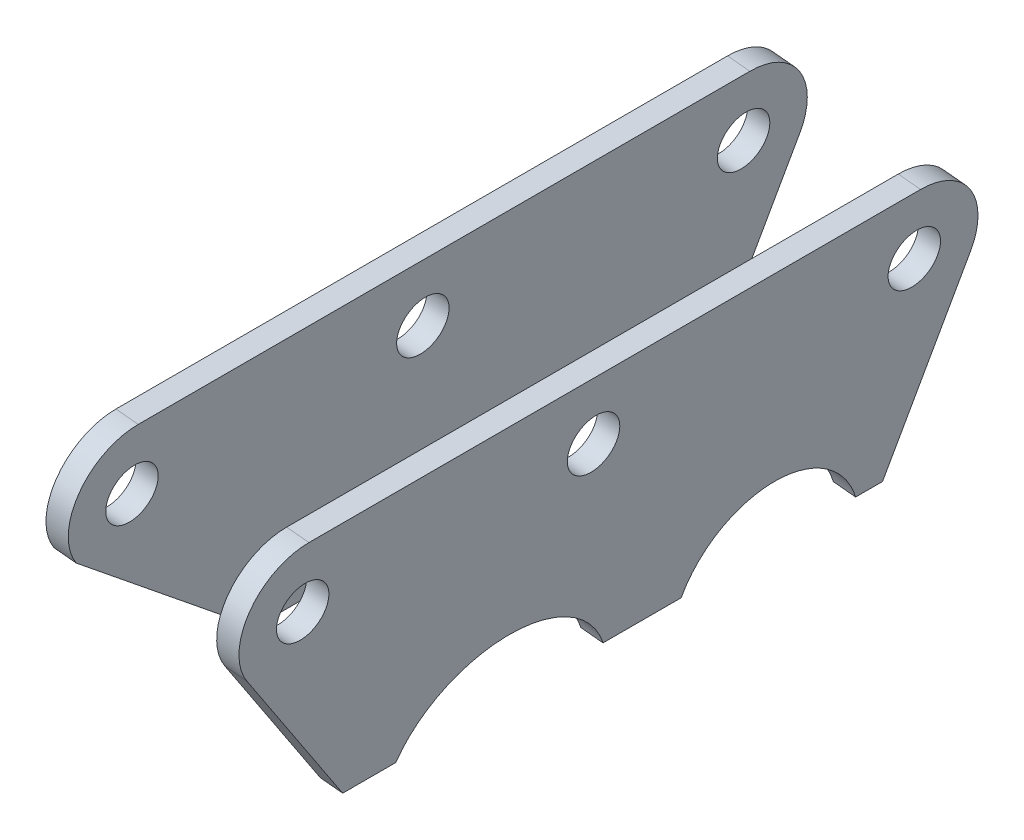
from build123d import *

# Parameters (mm, degrees)
SZKIC1_R                    = 3.5
DODANIE_WYCI_GNI_CIE1_DEPTH = 3
SZKIC2_R                    = 3.5
DODANIE_WYCI_GNI_CIE2_DEPTH = 3


with BuildPart() as part:
    # Szkic1 → Dodanie-wyciągnięcie1 (new body)
    with BuildSketch(Plane(origin=(1510.26539917, -150.162347119, 0), x_dir=(0, 0, -1), z_dir=(0.995093407, -0.098939936, 0))):
        with BuildLine():
            Line((-94, 389.244285112), (-176, 389.244285112))
            ThreePointArc((-176, 389.244285112), (-183.527682005, 384.691943106), (-182.99216801, 375.911109497))
            Line((-182.99216801, 375.911109497), (-168.015473067, 354.244285112))
            Line((-168.015473067, 354.244285112), (-160.885440505, 354.244285112))
            add(Edge.make_bspline(
                [(-160.885440505, 354.244285112), (-153.785636141, 368.019539208), (-137.697083979, 366.114436311), (-133.110394172, 354.244285112)],
                knots=[0.109763154, 0.109763154, 0.109763154, 0.109763154, 0.458625023, 0.458625023, 0.458625023, 0.458625023], degree=3, weights=[0.657330984, 0.39640678, 0.460028186, 0.848195201]))
            Line((-133.110394172, 354.244285112), (-122.632192473, 354.244285112))
            add(Edge.make_bspline(
                [(-122.632192473, 354.244285112), (-119.408973744, 362.626222554), (-111.475333465, 363.988172278), (-105.487616035, 361.094928434)],
                knots=[0.739553983, 0.739553983, 0.739553983, 0.739553983, 1, 1, 1, 1], degree=3, weights=[0.500872954, 0.486362962, 0.652738644, 1]))
            add(Edge.make_bspline(
                [(-105.487616035, 361.094928434), (-102.846358705, 359.818682251), (-100.484996274, 357.554609079), (-99.24420603, 354.244285112)],
                knots=[0, 0, 0, 0, 0.142552622, 0.142552622, 0.142552622, 0.142552622], degree=3, weights=[1, 0.809929837, 0.674049674, 0.592359511]))
            Line((-99.24420603, 354.244285112), (-95.633072844, 354.244285112))
            Line((-95.633072844, 354.244285112), (-86.130002131, 377.532878327))
            ThreePointArc((-86.130002131, 377.532878327), (-86.944967836, 385.485226069), (-94, 389.244285112))
        make_face()
        with Locations((-176, 380.744285112)):
            Circle(SZKIC1_R, mode=Mode.SUBTRACT)
        with Locations((-137, 380.744285112)):
            Circle(SZKIC1_R, mode=Mode.SUBTRACT)
        with Locations((-94, 380.744285112)):
            Circle(SZKIC1_R, mode=Mode.SUBTRACT)
    extrude(amount=-DODANIE_WYCI_GNI_CIE1_DEPTH)


with BuildPart() as body_2:
    # Szkic2 → Dodanie-wyciągnięcie2 (new body)
    with BuildSketch(Plane(origin=(1487.378250803, -147.886728596, 0), x_dir=(0, 0, -1), z_dir=(0.995093407, -0.098939936, 0))):
        with BuildLine():
            Line((-94, 389.244285112), (-176, 389.244285112))
            ThreePointArc((-176, 389.244285112), (-183.527682005, 384.691943106), (-182.99216801, 375.911109497))
            Line((-182.99216801, 375.911109497), (-156.840444696, 354.244285112))
            Line((-156.840444696, 354.244285112), (-146.921435672, 354.244285112))
            add(Edge.make_bspline(
                [(-146.921435672, 354.244285112), (-143.327169377, 367.52658758), (-127.980702926, 369.59903975), (-119.923911954, 359.478696835)],
                knots=[0.548877144, 0.548877144, 0.548877144, 0.548877144, 1, 1, 1, 1], degree=3, weights=[0.875864545, 0.535330773, 0.576709258, 1]))
            add(Edge.make_bspline(
                [(-119.923911954, 359.478696835), (-115.699468449, 365.269367694), (-109.261173327, 365.77778435), (-104.36745598, 363.413157469)],
                knots=[0.772719047, 0.772719047, 0.772719047, 0.772719047, 1, 1, 1, 1], degree=3, weights=[0.504129241, 0.531668476, 0.696958729, 1]))
            add(Edge.make_bspline(
                [(-104.36745598, 363.413157469), (-101.071249639, 361.820442245), (-98.258408522, 358.737930894), (-97.500362288, 354.244285112)],
                knots=[0, 0, 0, 0, 0.169893861, 0.169893861, 0.169893861, 0.169893861], degree=3, weights=[1, 0.773474852, 0.623920168, 0.551335948]))
            Line((-97.500362288, 354.244285112), (-95.633072844, 354.244285112))
            Line((-95.633072844, 354.244285112), (-86.130002131, 377.532878327))
            ThreePointArc((-86.130002131, 377.532878327), (-86.944967836, 385.485226069), (-94, 389.244285112))
        make_face()
        with Locations((-176, 380.744285112)):
            Circle(SZKIC2_R, mode=Mode.SUBTRACT)
        with Locations((-137, 380.744285112)):
            Circle(SZKIC2_R, mode=Mode.SUBTRACT)
        with Locations((-94, 380.744285112)):
            Circle(SZKIC2_R, mode=Mode.SUBTRACT)
    extrude(amount=-DODANIE_WYCI_GNI_CIE2_DEPTH)


solid = Compound([part.part, body_2.part])
